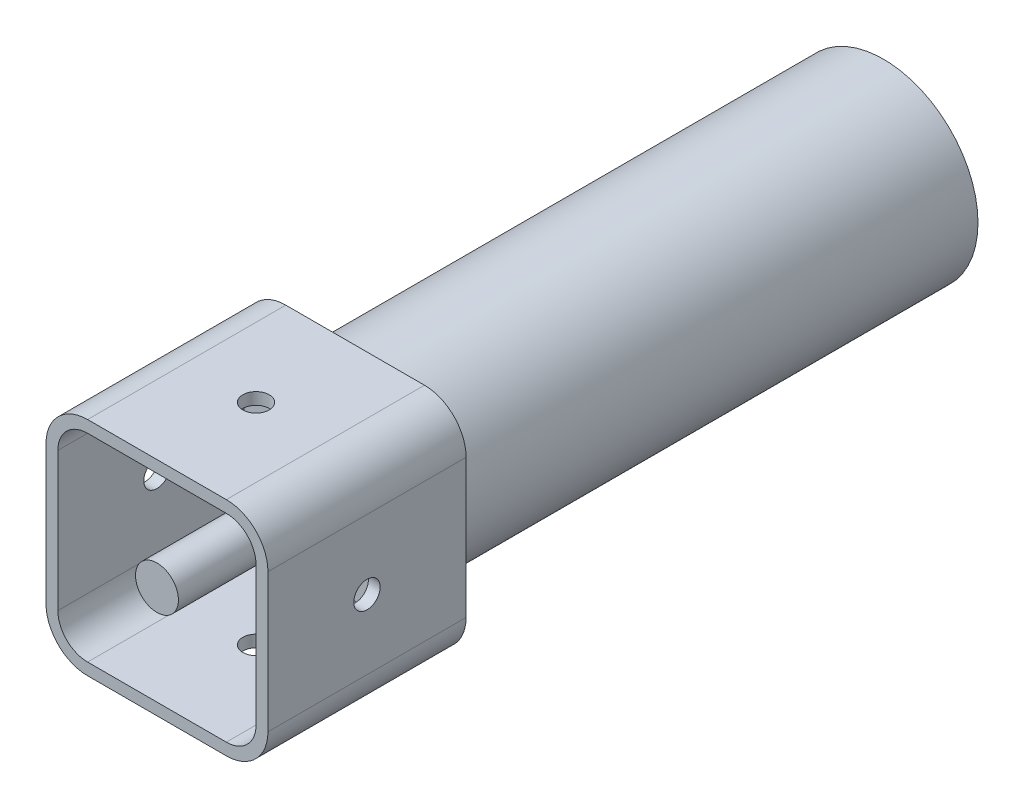
from build123d import *

# Parameters (mm, degrees)
EXTRUDE_1_DEPTH          = 30
SHELL_1_T                = -1.8
SKETCH_1_3_R             = 3.25
EXTRUDE_2_DEPTH          = 30
CUT_EXTRUDE_1_REACH      = 50.075
SKETCH_2_R               = 2
PATTERN_CIRCULAR_1_COUNT = 4
SKETCH_3_R               = 14.3
SKETCH_3_R_2             = 12.5
EXTRUDE_3_DEPTH          = 80
CUT_EXTRUDE_2_REACH      = 85.453
FILLET_1_R               = 2


with BuildPart() as part:
    # 草圖1 → 填料-伸長1 (new body)
    with BuildSketch(Plane.XY):
        with BuildLine():
            ThreePointArc((16.8, 10.5), (14.954772721, 14.954772721), (10.5, 16.8))
            Line((10.5, 16.8), (-10.5, 16.8))
            ThreePointArc((-10.5, 16.8), (-14.954772721, 14.954772721), (-16.8, 10.5))
            Line((-16.8, 10.5), (-16.8, -10.5))
            ThreePointArc((-16.8, -10.5), (-14.954772721, -14.954772721), (-10.5, -16.8))
            Line((-10.5, -16.8), (10.5, -16.8))
            ThreePointArc((10.5, -16.8), (14.954772721, -14.954772721), (16.8, -10.5))
            Line((16.8, -10.5), (16.8, 10.5))
        make_face()
    extrude(amount=EXTRUDE_1_DEPTH)

    # 薄殼1
    shell_1_openings = [part.faces().sort_by_distance(p)[0] for p in [
        (0, 0, 30),
    ]]
    offset(amount=SHELL_1_T, openings=shell_1_openings, kind=Kind.INTERSECTION)

    # 草圖1<3> → 填料-伸長2 (add)
    with BuildSketch(Plane.XY):
        Circle(SKETCH_1_3_R)
    extrude(amount=EXTRUDE_2_DEPTH)

    # 草圖2 → 除料-伸長1 (cut, up to next)
    with BuildSketch(Plane(origin=(0, 16.8, 0), x_dir=(1, 0, 0), z_dir=(0, 1, 0)), mode=Mode.PRIVATE) as cut_extrude_1_sk1:
        with Locations((0, -15)):
            Circle(SKETCH_2_R)
    cut_extrude_1_tool1 = extrude(cut_extrude_1_sk1.sketch, amount=-CUT_EXTRUDE_1_REACH, mode=Mode.PRIVATE) & part.part
    cut_extrude_1 = cut_extrude_1_tool1.solids().sort_by_distance((0, 16.8, 15))[0]
    add(cut_extrude_1, mode=Mode.SUBTRACT)

    # 環狀複製排列1: 除料-伸長1 ×4 about axis
    pattern_circular_1_axis = Axis((0, 0, 30), (0, 0, -1))
    for i in range(1, PATTERN_CIRCULAR_1_COUNT):
        add(cut_extrude_1.rotate(pattern_circular_1_axis, i * 360 / PATTERN_CIRCULAR_1_COUNT), mode=Mode.SUBTRACT)

    # 草圖3 → 填料-伸長3 (add)
    with BuildSketch(Plane(origin=(0, 0, 0), x_dir=(-1, 0, 0), z_dir=(0, 0, -1))):
        Circle(SKETCH_3_R)
        Circle(SKETCH_3_R_2, mode=Mode.SUBTRACT)
    extrude(amount=EXTRUDE_3_DEPTH)

    # 草圖4 → 除料-伸長2 (cut, up to next)
    with BuildSketch(Plane(origin=(0, 0, 0), x_dir=(1, 0, 0), z_dir=(0, 1, 0)), mode=Mode.PRIVATE) as cut_extrude_2_sk1:
        with BuildLine():
            Line((-2.5, 82.665609903), (2.5, 82.665609903))
            Line((2.5, 82.665609903), (2.5, 50))
            ThreePointArc((2.5, 50), (0, 47.5), (-2.5, 50))
            Line((-2.5, 50), (-2.5, 82.665609903))
        make_face()
    cut_extrude_2_tool1 = extrude(cut_extrude_2_sk1.sketch, amount=-CUT_EXTRUDE_2_REACH, mode=Mode.PRIVATE) & part.part
    add(cut_extrude_2_tool1.solids().sort_by_distance((0, 0, -65.346562))[0], mode=Mode.SUBTRACT)

    # 圓角1
    fillet_1_edges = [part.edges().sort_by_distance(p)[0] for p in [
        (14.3, 0, 0),
    ]]
    fillet(fillet_1_edges, radius=FILLET_1_R)


solid = part.part
